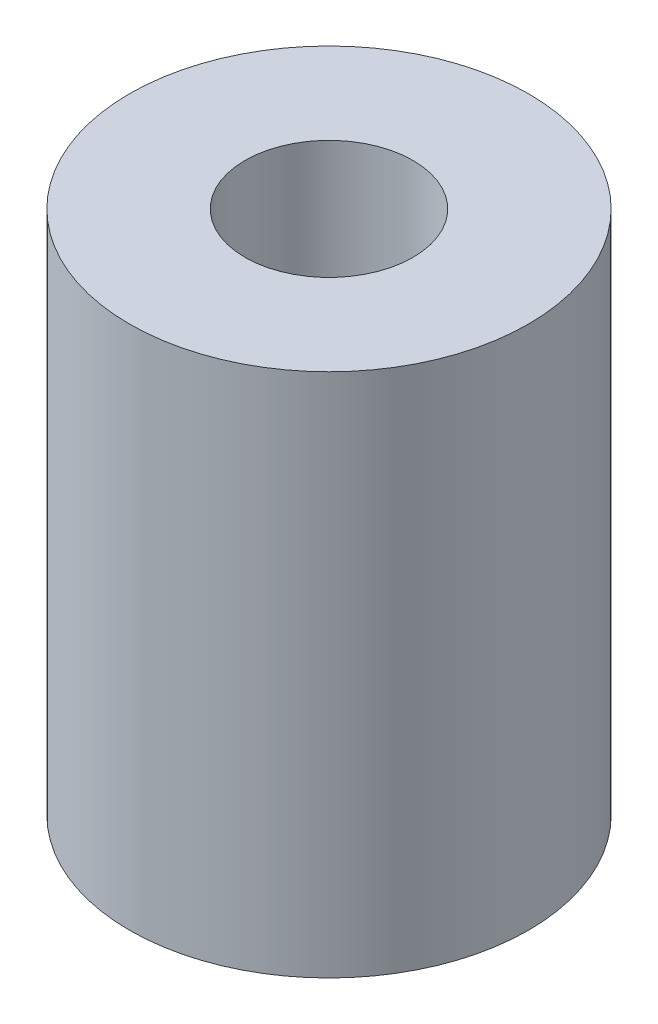
from build123d import *

# Parameters (mm, degrees)
ESBO_O1_R                = 9.5
RESSALTO_EXTRUS_O1_DEPTH = 25
ESBO_O2_R                = 4
CORTE_EXTRUS_O1_DEPTH    = 12.5
ESBO_O3_R                = 2.5
CORTE_EXTRUS_O2_DEPTH    = 12.5


with BuildPart() as part:
    # Esboço1 → Ressalto-extrusão1 (new body)
    with BuildSketch(Plane(origin=(0, 0, 0), x_dir=(1, 0, 0), z_dir=(0, 1, 0))):
        Circle(ESBO_O1_R)
    extrude(amount=RESSALTO_EXTRUS_O1_DEPTH)

    # Esboço2 → Corte-extrusão1 (cut)
    with BuildSketch(Plane(origin=(0, 25, 0), x_dir=(1, 0, 0), z_dir=(0, 1, 0))):
        Circle(ESBO_O2_R)
    extrude(amount=-CORTE_EXTRUS_O1_DEPTH, mode=Mode.SUBTRACT)

    # Esboço3 → Corte-extrusão2 (cut)
    with BuildSketch(Plane(origin=(0, 0, 0), x_dir=(-1, 0, 0), z_dir=(0, -1, 0))):
        Circle(ESBO_O3_R)
    extrude(amount=-CORTE_EXTRUS_O2_DEPTH, mode=Mode.SUBTRACT)


solid = part.part
